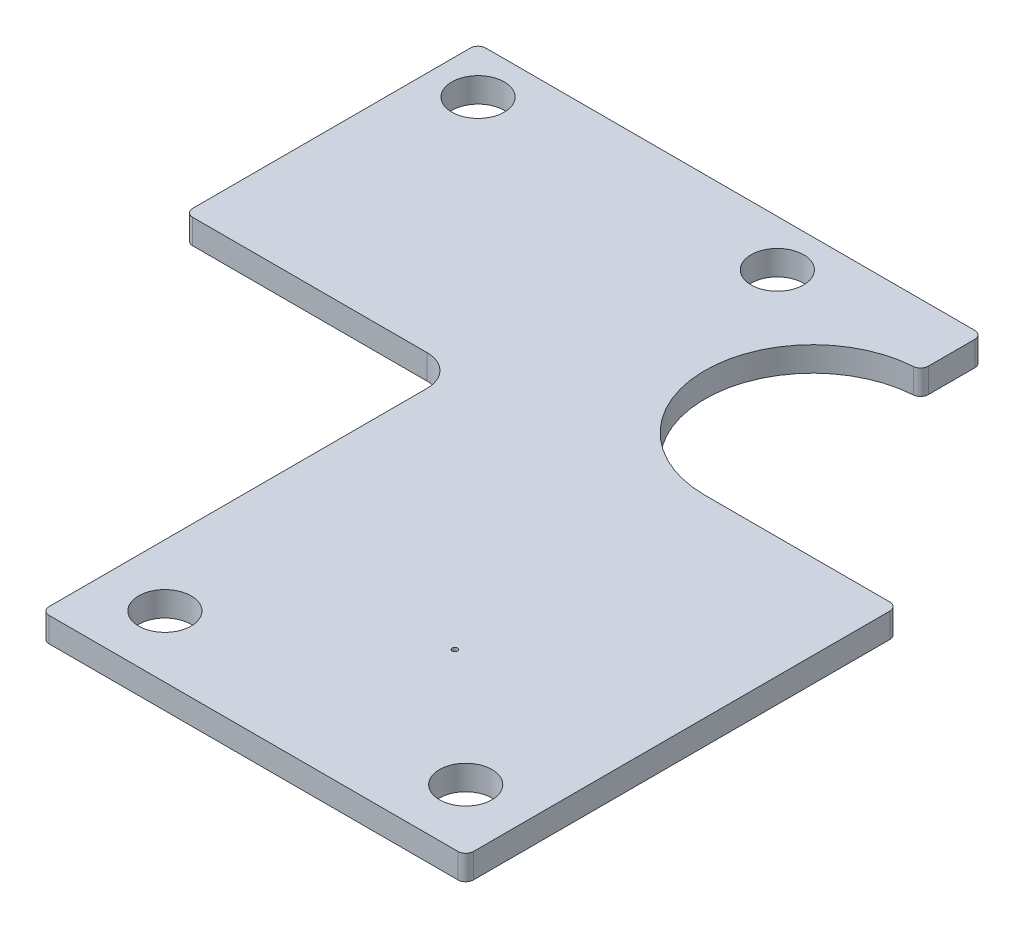
from build123d import *

# Parameters (mm, degrees)
BOSS_EXTRUDE1_DEPTH  = 1.6
FILLET1_R            = 0.5
FILLET2_R            = 2
M3_CLEARANCE_HOLE1_D = 3.4
SKETCH4_R            = 0.175
CUT_EXTRUDE1_DEPTH   = 2.6


with BuildPart() as part:
    # Sketch1 → Boss-Extrude1 (new body)
    with BuildSketch(Plane(origin=(0, 0, 0), x_dir=(1, 0, 0), z_dir=(0, 1, 0))):
        with BuildLine():
            Line((0.032553291, 32.590082792), (0.032553291, 51.590082792))
            Line((0.032553291, 51.590082792), (32.732553291, 51.590082792))
            Line((32.732553291, 51.590082792), (32.732553291, 47.590082792))
            ThreePointArc((32.732553291, 47.590082792), (25.732553291, 40.590082792), (32.732553291, 33.590082792))
            Line((32.732553291, 33.590082792), (45.232553291, 33.590082792))
            Line((45.232553291, 33.590082792), (45.232553291, 5.590082792))
            Line((45.232553291, 5.590082792), (17.732553291, 5.590082792))
            Line((17.732553291, 5.590082792), (17.732553291, 32.590082792))
            Line((17.732553291, 32.590082792), (0.032553291, 32.590082792))
        make_face()
    extrude(amount=BOSS_EXTRUDE1_DEPTH)

    # Fillet1
    fillet1_edges = [part.edges().sort_by_distance(p)[0] for p in [
        (32.732553291, 0.8, -51.590082792),
        (32.732553291, 0.8, -47.590082792),
        (45.232553291, 0.8, -33.590082792),
        (45.232553291, 0.8, -5.590082792),
        (17.732553291, 0.8, -5.590082792),
        (0.032553291, 0.8, -32.590082792),
        (0.032553291, 0.8, -51.590082792),
    ]]
    fillet(fillet1_edges, radius=FILLET1_R)

    # Fillet2
    fillet2_edges = [part.edges().sort_by_distance(p)[0] for p in [
        (17.732553291, 0.8, -32.590082792),
    ]]
    fillet(fillet2_edges, radius=FILLET2_R)

    # M3 Clearance Hole1 (through all)
    with Locations(Plane(origin=(0, 1.6, 0), x_dir=(1, 0, 0), z_dir=(0, 1, 0))):
        with Locations((3.032553291, 48.590082792), (22.432553291, 48.590082792), (21.732553291, 9.590082792), (41.232553291, 9.590082792)):
            Hole(M3_CLEARANCE_HOLE1_D / 2)

    # Sketch4 → Cut-Extrude1 (cut, through all)
    with BuildSketch(Plane(origin=(0, 1.6, 0), x_dir=(1, 0, 0), z_dir=(0, 1, 0))):
        with Locations((33.297557825, 16.825078258)):
            Circle(SKETCH4_R)
    extrude(amount=-CUT_EXTRUDE1_DEPTH, mode=Mode.SUBTRACT)


solid = part.part
